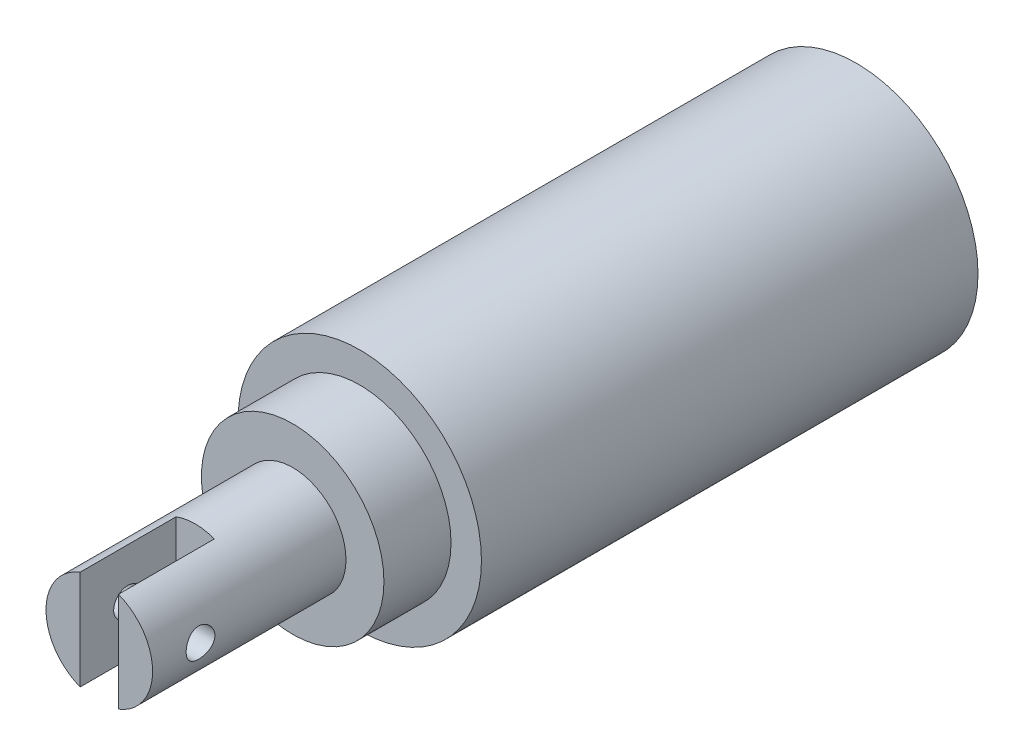
from build123d import *

# Parameters (mm, degrees)
SKETCH1_R               = 12.7
EXTRUDE1_DEPTH          = 51.816
SKETCH2_R               = 9.525
EXTRUDE2_DEPTH          = 7
SKETCH3_R               = 5.5626
EXTRUDE3_DEPTH          = 20.178
SKETCH4_W               = 4
SKETCH4_H               = 12
CUT_EXTRUDE1_DEPTH      = 10
SKETCH5_R               = 1.5
CUT_EXTRUDE2_DEPTH      = 10
CUT_EXTRUDE2_DEPTH_BACK = 10


with BuildPart() as part:
    # Sketch1 → Extrude1 (new body)
    with BuildSketch(Plane.XY):
        Circle(SKETCH1_R)
    extrude(amount=EXTRUDE1_DEPTH)

    # Sketch2 → Extrude2 (add)
    with BuildSketch(Plane.XY.offset(51.816)):
        Circle(SKETCH2_R)
    extrude(amount=EXTRUDE2_DEPTH)

    # Sketch3 → Extrude3 (add)
    with BuildSketch(Plane.XY.offset(58.816)):
        Circle(SKETCH3_R)
    extrude(amount=EXTRUDE3_DEPTH)

    # Sketch4 → Cut-Extrude1 (cut)
    with BuildSketch(Plane.XY.offset(78.994)):
        Rectangle(SKETCH4_W, SKETCH4_H)
    extrude(amount=-CUT_EXTRUDE1_DEPTH, mode=Mode.SUBTRACT)

    # Sketch5 → Cut-Extrude2 (cut, two sides)
    with BuildSketch(Plane.ZY.offset(-2)) as cut_extrude2_sk:
        with Locations((73.994, 0.000618341)):
            Circle(SKETCH5_R)
    extrude(amount=CUT_EXTRUDE2_DEPTH, mode=Mode.SUBTRACT)
    extrude(cut_extrude2_sk.sketch, amount=-CUT_EXTRUDE2_DEPTH_BACK, mode=Mode.SUBTRACT)


solid = part.part
